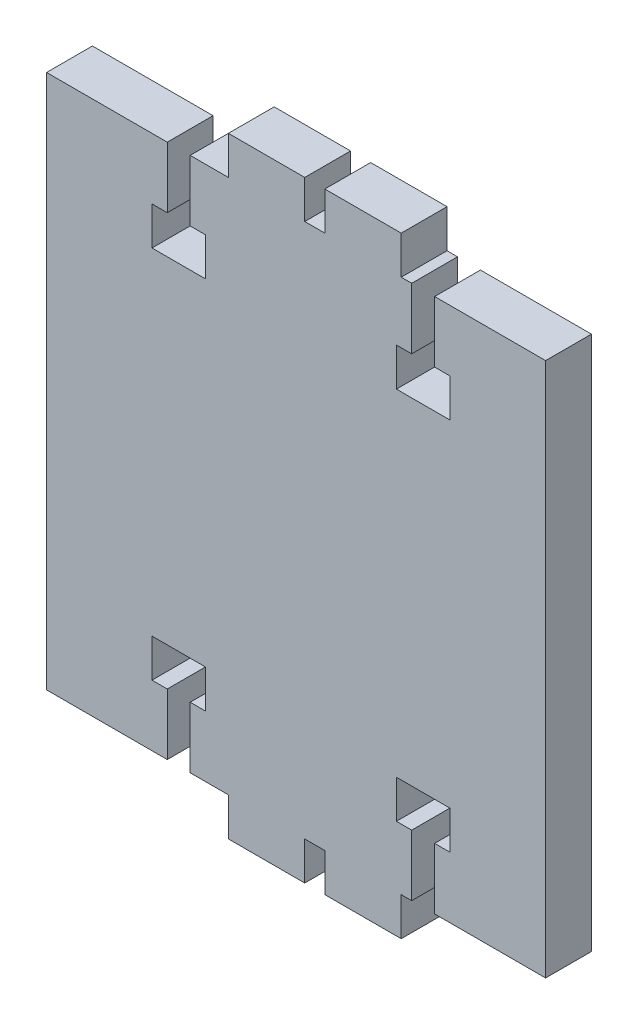
from build123d import *

# Parameters (mm, degrees)
RESSALTO_EXTRUS_O1_DEPTH = 6


with BuildPart() as part:
    # Model → Ressalto-extrusão1 (new body)
    with BuildSketch(Plane.XY):
        Polygon((-49.531, 62), (-49.531, 70), (-65.331, 70), (-65.331, 0), (-49.531, 0), (-49.531, 8), (-51.531, 8), (-51.531, 13), (-44.531, 13), (-44.531, 8), (-46.531, 8), (-46.531, 0), (-41.532192214, 0), (-41.532192214, -5), (-31.532192214, -5), (-31.532192214, 0), (-28.904333594, 0), (-28.904333594, -5), (-18.904333594, -5), (-18.904333594, 0), (-17.531, 0), (-17.531, 8), (-19.531, 8), (-19.531, 13), (-12.531, 13), (-12.531, 8), (-14.531, 8), (-14.531, 0), (0, 0), (0, 70), (-14.531, 70), (-14.531, 62), (-12.531, 62), (-12.531, 57), (-19.531, 57), (-19.531, 62), (-17.531, 62), (-17.531, 70), (-18.904, 70), (-18.904, 75), (-28.904, 75), (-28.904, 70), (-31.532, 70), (-31.532, 75), (-41.532, 75), (-41.532, 70), (-46.531, 70), (-46.531, 62), (-44.531, 62), (-44.531, 57), (-51.531, 57), (-51.531, 62), align=None)
    extrude(amount=RESSALTO_EXTRUS_O1_DEPTH)


solid = part.part
